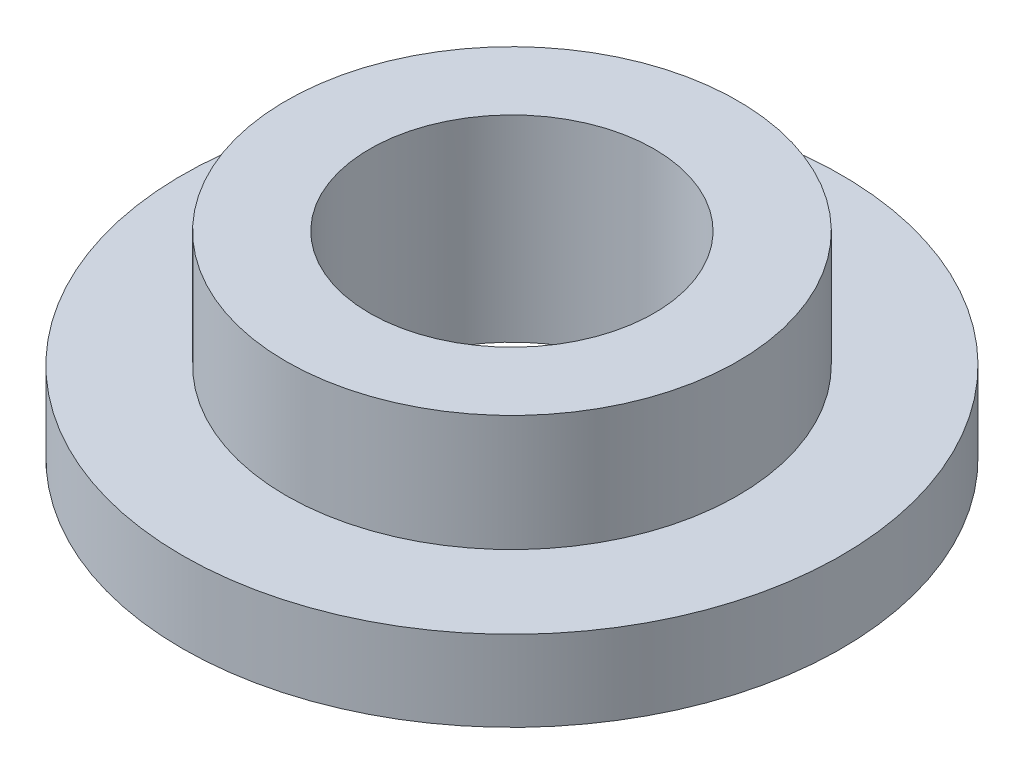
from build123d import *

# Parameters (mm, degrees)
SKETCH1_R           = 13.9
BOSS_EXTRUDE1_DEPTH = 3.4
SKETCH2_R           = 9.525
BOSS_EXTRUDE2_DEPTH = 4.9
SKETCH3_R           = 6
CUT_EXTRUDE1_DEPTH  = 8.3


with BuildPart() as part:
    # Sketch1 → Boss-Extrude1 (new body)
    with BuildSketch(Plane(origin=(0, 0, 0), x_dir=(1, 0, 0), z_dir=(0, 1, 0))):
        Circle(SKETCH1_R)
    extrude(amount=BOSS_EXTRUDE1_DEPTH)

    # Sketch2 → Boss-Extrude2 (add)
    with BuildSketch(Plane(origin=(0, 3.4, 0), x_dir=(1, 0, 0), z_dir=(0, 1, 0))):
        Circle(SKETCH2_R)
    extrude(amount=BOSS_EXTRUDE2_DEPTH)

    # Sketch3 → Cut-Extrude1 (cut)
    with BuildSketch(Plane.XZ):
        Circle(SKETCH3_R)
    extrude(amount=-CUT_EXTRUDE1_DEPTH, mode=Mode.SUBTRACT)


solid = part.part
